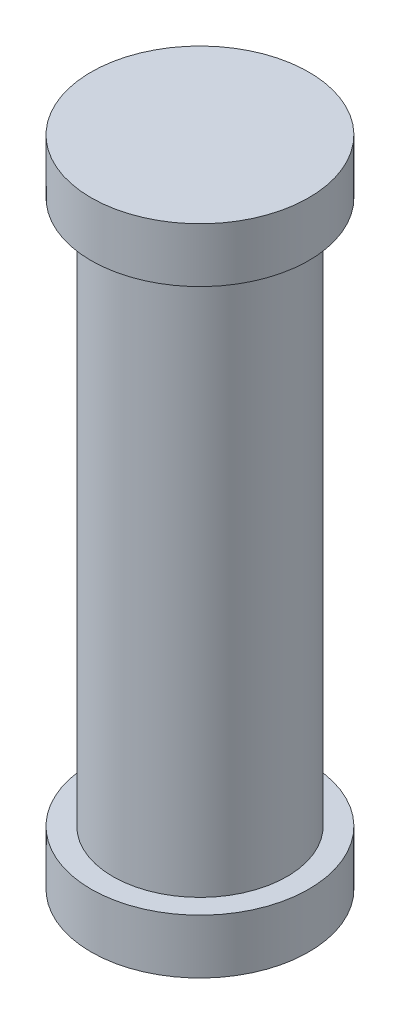
from build123d import *

# Parameters (mm, degrees)
SKETCH1_R           = 2
BOSS_EXTRUDE1_DEPTH = 1
SKETCH2_R           = 1.6
BOSS_EXTRUDE2_DEPTH = 10
SKETCH3_R           = 2
BOSS_EXTRUDE3_DEPTH = 1


with BuildPart() as part:
    # Sketch1 → Boss-Extrude1 (new body)
    with BuildSketch(Plane(origin=(0, 0, 0), x_dir=(1, 0, 0), z_dir=(0, 1, 0))):
        Circle(SKETCH1_R)
    extrude(amount=BOSS_EXTRUDE1_DEPTH)

    # Sketch2 → Boss-Extrude2 (add)
    with BuildSketch(Plane(origin=(0, 1, 0), x_dir=(1, 0, 0), z_dir=(0, 1, 0))):
        Circle(SKETCH2_R)
    extrude(amount=BOSS_EXTRUDE2_DEPTH)

    # Sketch3 → Boss-Extrude3 (add)
    with BuildSketch(Plane(origin=(0, 11, 0), x_dir=(1, 0, 0), z_dir=(0, 1, 0))):
        Circle(SKETCH3_R)
    extrude(amount=BOSS_EXTRUDE3_DEPTH)


solid = part.part
